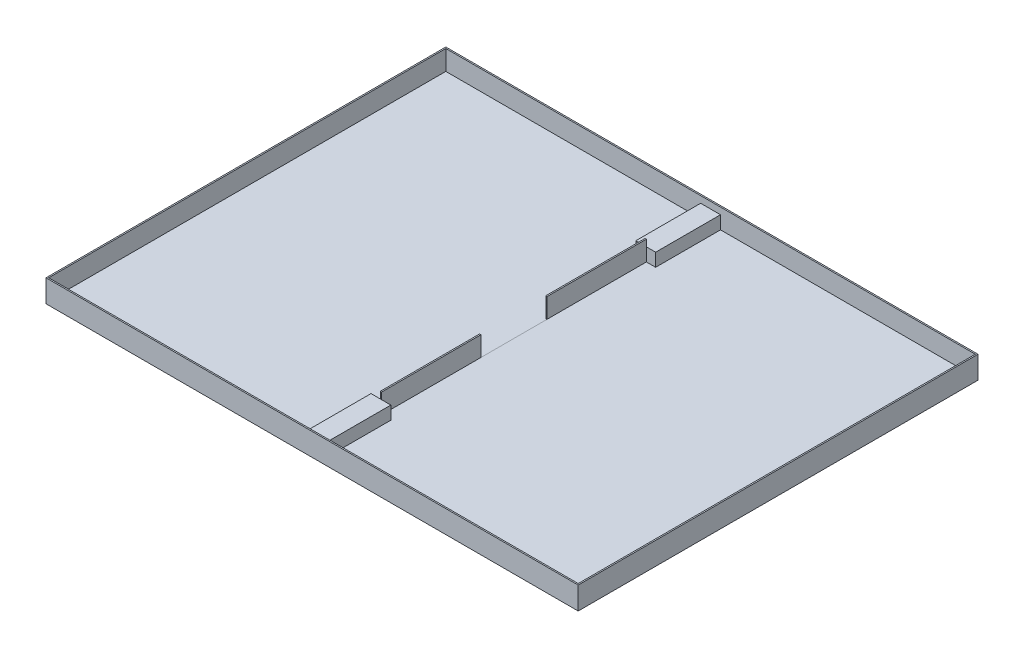
from build123d import *

# Parameters (mm, degrees)
ESBO_O1_W                = 4020
ESBO_O1_H                = 20
RESSALTO_EXTRUS_O1_DEPTH = 3020
ESBO_O2_W                = 4020
ESBO_O2_H                = 3020
ESBO_O2_W_2              = 4000
ESBO_O2_H_2              = 3000
ESBO_O2_W_3              = 10
ESBO_O2_H_3              = 750
RESSALTO_EXTRUS_O2_DEPTH = 150
ESBO_O3_W                = 150
ESBO_O3_H                = 490
ESBO_O3_H_2              = 510
RESSALTO_EXTRUS_O3_DEPTH = 100
ESBO_O4_W                = 1995
ESBO_O4_H                = 3000
RESSALTO_EXTRUS_O4_DEPTH = 1


with BuildPart() as part:
    # Esboço1 → Ressalto-extrusão1 (new body)
    with BuildSketch(Plane.XY):
        with Locations((1169.753435213, -142.12327558)):
            Rectangle(ESBO_O1_W, ESBO_O1_H)
    extrude(amount=RESSALTO_EXTRUS_O1_DEPTH)

    # Esboço2 → Ressalto-extrusão2 (add)
    with BuildSketch(Plane(origin=(0, -132.12327558, 0), x_dir=(1, 0, 0), z_dir=(0, 1, 0))):
        with Locations((1169.753435213, -1510)):
            Rectangle(ESBO_O2_W, ESBO_O2_H)
        with Locations((1169.753435213, -1510)):
            Rectangle(ESBO_O2_W_2, ESBO_O2_H_2, mode=Mode.SUBTRACT)
        with Locations((1169.753435213, -875)):
            Rectangle(ESBO_O2_W_3, ESBO_O2_H_3)
        with Locations((1169.753435213, -2125)):
            Rectangle(ESBO_O2_W_3, ESBO_O2_H_3)
    extrude(amount=RESSALTO_EXTRUS_O2_DEPTH)

    # Esboço3 → Ressalto-extrusão3 (add)
    with BuildSketch(Plane(origin=(0, -132.12327558, 0), x_dir=(1, 0, 0), z_dir=(0, 1, 0))):
        with Locations((1169.753435213, -255)):
            Rectangle(ESBO_O3_W, ESBO_O3_H)
        with Locations((1169.753435213, -2755)):
            Rectangle(ESBO_O3_W, ESBO_O3_H_2)
    extrude(amount=RESSALTO_EXTRUS_O3_DEPTH)

    # Esboço4 → Ressalto-extrusão4 (add)
    with BuildSketch(Plane(origin=(0, -132.12327558, 0), x_dir=(1, 0, 0), z_dir=(0, 1, 0))):
        with Locations((2172.253435213, -1510)):
            Rectangle(ESBO_O4_W, ESBO_O4_H)
    extrude(amount=RESSALTO_EXTRUS_O4_DEPTH)


solid = part.part
